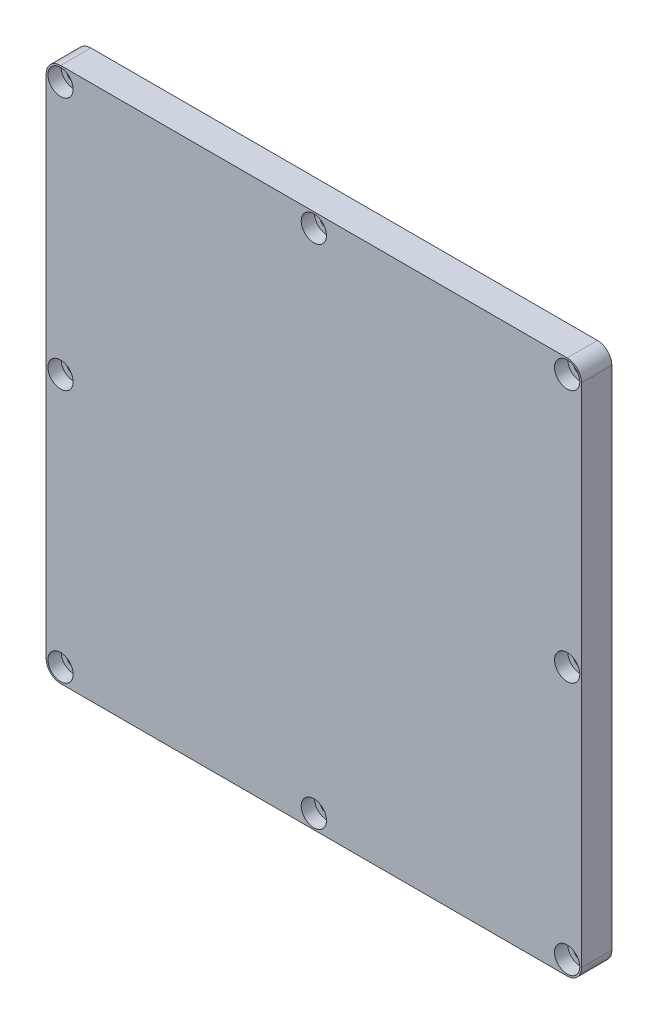
from build123d import *

# Parameters (mm, degrees)
SKETCH1_W                                      = 168.275
SKETCH1_H                                      = 168.275
BOSS_EXTRUDE1_DEPTH                            = 9.525
CBORE_FOR_8_SOCKET_HEAD_CAP_SCREW1_D           = 4.4958
CBORE_FOR_8_SOCKET_HEAD_CAP_SCREW1_CBORE_D     = 7.9375
CBORE_FOR_8_SOCKET_HEAD_CAP_SCREW1_CBORE_DEPTH = 4.1656
FILLET1_R                                      = 4.5212


with BuildPart() as part:
    # Sketch1 → Boss-Extrude1 (new body)
    with BuildSketch(Plane.XY):
        Rectangle(SKETCH1_W, SKETCH1_H)
    extrude(amount=BOSS_EXTRUDE1_DEPTH)

    # CBORE for #8 Socket Head Cap Screw1 (through all)
    with Locations(Plane.XY.offset(9.525)):
        with Locations((-79.629, 79.629), (0, 79.629), (79.629, 79.629), (79.629, 0), (0, -79.629), (79.629, -79.629), (-79.629, 0), (-79.629, -79.629)):
            CounterBoreHole(CBORE_FOR_8_SOCKET_HEAD_CAP_SCREW1_D / 2, CBORE_FOR_8_SOCKET_HEAD_CAP_SCREW1_CBORE_D / 2, CBORE_FOR_8_SOCKET_HEAD_CAP_SCREW1_CBORE_DEPTH)

    # Fillet1
    fillet1_edges = [part.edges().sort_by_distance(p)[0] for p in [
        (-84.1375, 84.1375, 4.7625),
        (84.1375, 84.1375, 4.7625),
        (84.1375, -84.1375, 4.7625),
        (-84.1375, -84.1375, 4.7625),
    ]]
    fillet(fillet1_edges, radius=FILLET1_R)


solid = part.part
